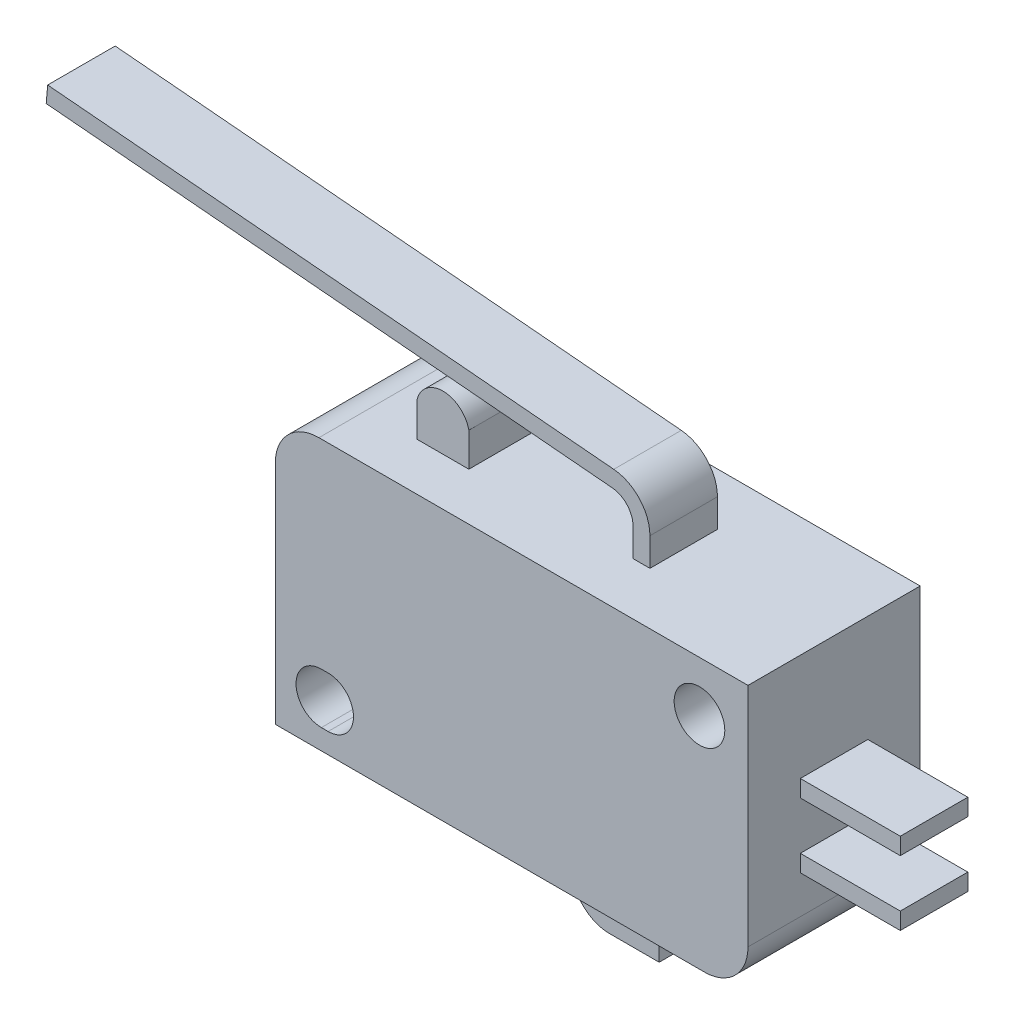
from build123d import *

# Parameters (mm, degrees)
BOSS_EXTRUDE1_DEPTH = 5.1
SKETCH2_R           = 1.5
CUT_EXTRUDE1_DEPTH  = 11.2
SKETCH3_W           = 3.075451665
SKETCH3_H           = 4.554021572
BOSS_EXTRUDE2_DEPTH = 2
BOSS_EXTRUDE3_DEPTH = 4.554022
SKETCH5_W           = 5.923073673
SKETCH5_H           = 1
EXTRUDE_THIN1_DEPTH = 2


with BuildPart() as part:
    # Sketch1 → Boss-Extrude1 (new body, symmetric)
    with BuildSketch(Plane.XY):
        with BuildLine():
            Line((0, 0), (25.41820823, 0))
            ThreePointArc((25.41820823, 0), (27.243810698, 0.756189302), (28, 2.58179177))
            Line((28, 2.58179177), (28, 16))
            Line((28, 16), (2.58179177, 16))
            ThreePointArc((2.58179177, 16), (0.756189302, 15.243810698), (0, 13.41820823))
            Line((0, 13.41820823), (0, 0))
        make_face()
    extrude(amount=BOSS_EXTRUDE1_DEPTH, both=True)

    # Sketch2 → Cut-Extrude1 (cut, through all)
    with BuildSketch(Plane.XY.offset(5.1)):
        with Locations((25.126078894, 12.998288548)):
            Circle(SKETCH2_R)
        with BuildLine():
            Line((2.726078894, 4.198288548), (3.126078894, 4.198288548))
            ThreePointArc((3.126078894, 4.198288548), (4.626078894, 2.698288548), (3.126078894, 1.198288548))
            Line((3.126078894, 1.198288548), (2.726078894, 1.198288548))
            ThreePointArc((2.726078894, 1.198288548), (1.226078894, 2.698288548), (2.726078894, 4.198288548))
        make_face()
    extrude(amount=-CUT_EXTRUDE1_DEPTH, mode=Mode.SUBTRACT)

    # Sketch3 → Boss-Extrude2 (add)
    with BuildSketch(Plane(origin=(0, 16, 0), x_dir=(1, 0, 0), z_dir=(0, 1, 0))):
        with Locations((7.103184887, 0)):
            Rectangle(SKETCH3_W, SKETCH3_H)
    extrude(amount=BOSS_EXTRUDE2_DEPTH)

    # Sketch4 → Boss-Extrude3 (add)
    with BuildSketch(Plane(origin=(0, 0, 2.277010786), x_dir=(-1, 0, 0), z_dir=(0, 0, -1))):
        with BuildLine():
            Line((-8.640910719, 18), (-5.565459054, 18))
            ThreePointArc((-5.565459054, 18), (-7.103184886, 19.241645654), (-8.640910719, 18))
        make_face()
    extrude(amount=BOSS_EXTRUDE3_DEPTH)

    # Sketch5 → Extrude-Thin1 (add, symmetric)
    with BuildSketch(Plane.XY):
        with BuildLine():
            Line((18.090606696, 16), (18.090606696, 17.673346876))
            ThreePointArc((18.090606696, 17.673346876), (17.736957385, 18.583040478), (16.861731376, 19.015000796))
            Line((16.861731376, 19.015000796), (-16.676926327, 21.963605838))
            Line((-16.676926327, 21.963605838), (-16.58934753, 22.959763433))
            Line((-16.58934753, 22.959763433), (16.949310173, 20.011158391))
            ThreePointArc((16.949310173, 20.011158391), (18.474378159, 19.258474117), (19.090606696, 17.673346876))
            Line((19.090606696, 17.673346876), (19.090606696, 16))
            Line((19.090606696, 16), (18.090606696, 16))
        make_face()
        with BuildLine():
            Line((15.470256996, 0), (15.470256996, -1.706861363))
            ThreePointArc((15.470256996, -1.706861363), (15.830378815, -2.576272343), (16.699789795, -2.936394162))
            Line((16.699789795, -2.936394162), (19.638532844, -2.936394162))
            Line((19.638532844, -2.936394162), (19.638532844, -3.936394162))
            Line((19.638532844, -3.936394162), (16.699789795, -3.936394162))
            ThreePointArc((16.699789795, -3.936394162), (15.123272034, -3.283379124), (14.470256996, -1.706861363))
            Line((14.470256996, -1.706861363), (14.470256996, 0))
            Line((14.470256996, 0), (15.470256996, 0))
        make_face()
        with Locations((30.961536837, 9.17393674)):
            Rectangle(SKETCH5_W, SKETCH5_H)
        with Locations((30.961536837, 5.333502812)):
            Rectangle(SKETCH5_W, SKETCH5_H)
    extrude(amount=EXTRUDE_THIN1_DEPTH, both=True)


solid = part.part
